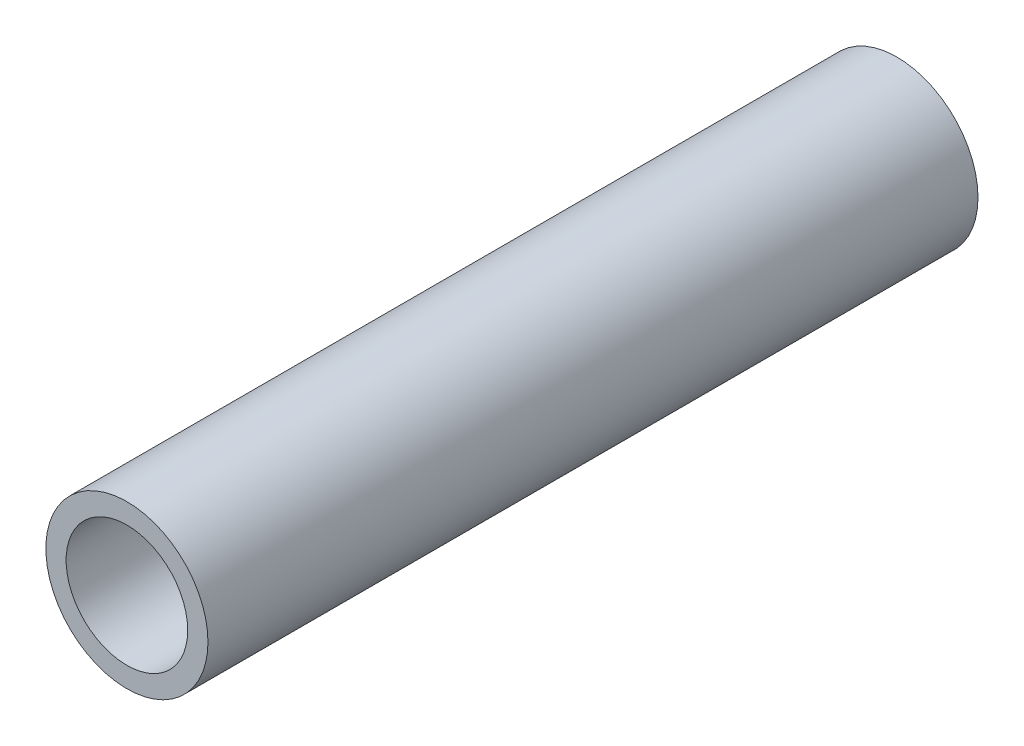
from build123d import *

# Parameters (mm, degrees)
CROQUIS1_R              = 4
CROQUIS1_R_2            = 3
SALIENTE_EXTRUIR1_DEPTH = 38


with BuildPart() as part:
    # Croquis1 → Saliente-Extruir1 (new body)
    with BuildSketch(Plane.XY):
        Circle(CROQUIS1_R)
        Circle(CROQUIS1_R_2, mode=Mode.SUBTRACT)
    extrude(amount=SALIENTE_EXTRUIR1_DEPTH)


solid = part.part
